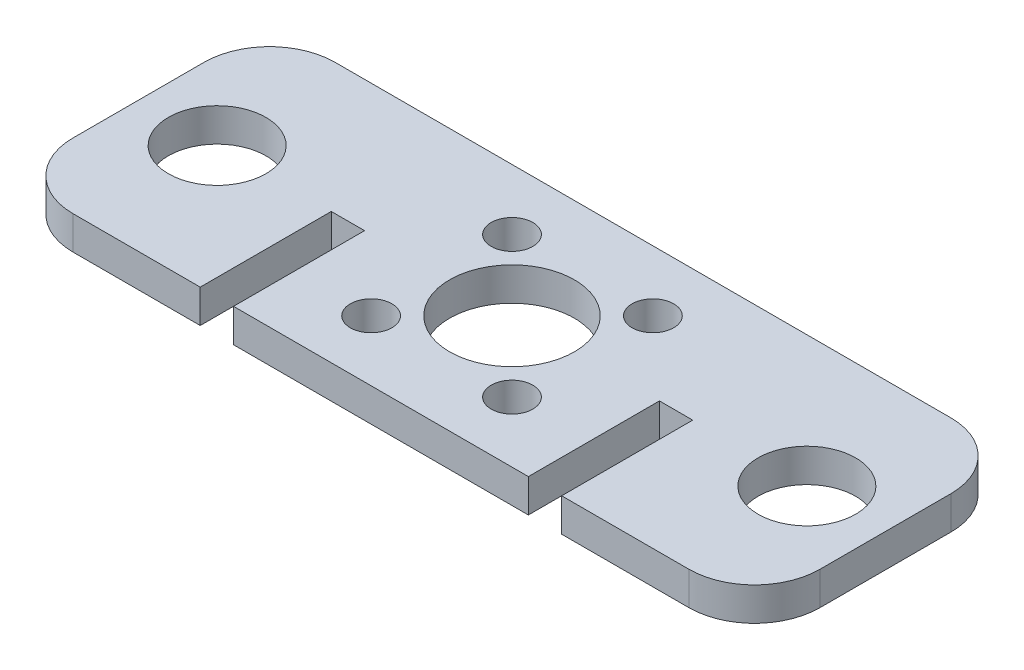
from build123d import *

# Parameters (mm, degrees)
SKETCH1_W           = 114
SKETCH1_H           = 40
SKETCH1_R           = 7.45
SKETCH1_R_2         = 9.525
BOSS_EXTRUDE1_DEPTH = 5.08
FILLET1_R           = 10
SKETCH2_R           = 3.175
SKETCH2_W           = 5.08
SKETCH2_H           = 20
CUT_EXTRUDE1_DEPTH  = 6.08


with BuildPart() as part:
    # Sketch1 → Boss-Extrude1 (new body)
    with BuildSketch(Plane(origin=(0, 0, 0), x_dir=(1, 0, 0), z_dir=(0, 1, 0))):
        Rectangle(SKETCH1_W, SKETCH1_H)
        with Locations((-45, 0)):
            Circle(SKETCH1_R, mode=Mode.SUBTRACT)
        with Locations((45, 0)):
            Circle(SKETCH1_R, mode=Mode.SUBTRACT)
        Circle(SKETCH1_R_2, mode=Mode.SUBTRACT)
    extrude(amount=BOSS_EXTRUDE1_DEPTH)

    # Fillet1
    fillet1_edges = [part.edges().sort_by_distance(p)[0] for p in [
        (-57, 2.54, -20),
        (57, 2.54, -20),
        (57, 2.54, 20),
        (-57, 2.54, 20),
    ]]
    fillet(fillet1_edges, radius=FILLET1_R)

    # Sketch2 → Cut-Extrude1 (cut, through all)
    with BuildSketch(Plane(origin=(0, 5.08, 0), x_dir=(1, 0, 0), z_dir=(0, 1, 0))):
        with Locations((10.75, -10.75)):
            Circle(SKETCH2_R)
        with Locations((-10.75, -10.75)):
            Circle(SKETCH2_R)
        with Locations((-10.75, 10.75)):
            Circle(SKETCH2_R)
        with Locations((10.75, 10.75)):
            Circle(SKETCH2_R)
        with Locations((-25.04, -10)):
            Rectangle(SKETCH2_W, SKETCH2_H)
        with Locations((25.04, -10)):
            Rectangle(SKETCH2_W, SKETCH2_H)
    extrude(amount=-CUT_EXTRUDE1_DEPTH, mode=Mode.SUBTRACT)


solid = part.part
